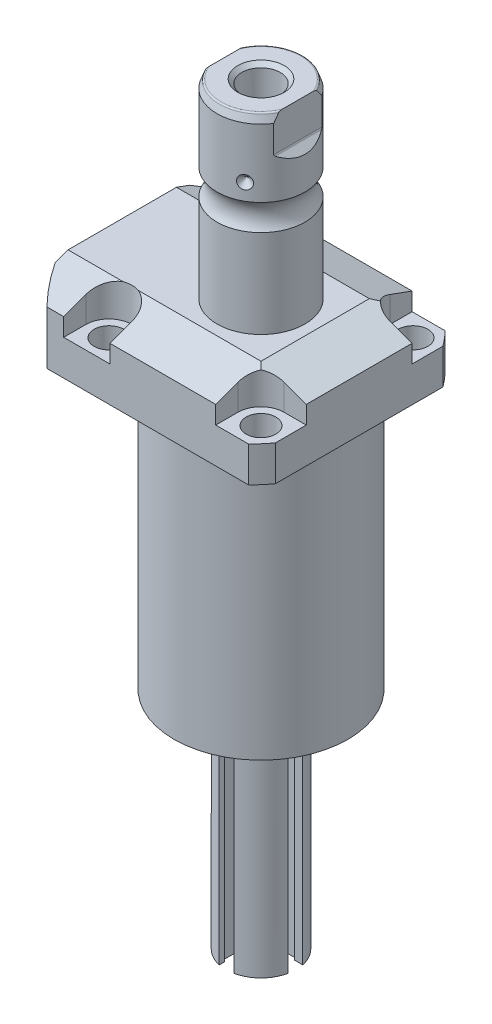
from build123d import *

# Parameters (mm, degrees)
SKETCH1_W                = 70.866
SKETCH1_H                = 85.496
EXTRUDE1_DEPTH           = 122.047
SKETCH2_OUTSIDE_W        = 120.498
SKETCH2_OUTSIDE_H        = 105.868
SKETCH2_OUTSIDE_R        = 50.8
CUT_EXTRUDE1_DEPTH       = 123.047
SKETCH3_W                = 45.1992
SKETCH3_H                = 97.028
FILLET1_R                = 0.381
CUT_EXTRUDE2_DEPTH       = 12.243
CUT_EXTRUDE9_START       = -51.063
CUT_EXTRUDE9_DEPTH       = 87.496
CUT_EXTRUDE7_DEPTH       = 36.433
CUT_EXTRUDE7_DEPTH_BACK  = 36.433
SKETCH10_R               = 1.1811
SKETCH17_W               = 5.3594
SKETCH17_H               = 12.776
HOLE1_AT_2_COUNT         = 2
HOLE1_AT_2_PITCH         = 54.864
HOLE1_AT_3_COUNT         = 2
HOLE1_AT_3_PITCH         = 77.589412886
HOLE1_AT_4_COUNT         = 2
HOLE1_AT_4_PITCH         = 54.864
CHAMFER1_SIZE            = 0.635
FILLET2_R                = 0.635
CIRPATTERN1_COUNT        = 3
CUT_EXTRUDE10_DEPTH      = 36.433
CUT_EXTRUDE10_DEPTH_BACK = 36.433
CHAMFER2_SIZE            = 1.4351
SKETCH33_R               = 2.7051
BOSS_EXTRUDE1_DEPTH      = 2.9972
CIRPATTERN2_COUNT        = 3
CUT_EXTRUDE11_DEPTH      = 70.612
CIRPATTERN3_COUNT        = 4
SKETCH35_R               = 3.4925
CUT_EXTRUDE15_DEPTH      = 7.62
CIRPATTERN4_COUNT        = 4
CUT_EXTRUDE16_DEPTH      = 1.27
CIRPATTERN5_COUNT        = 3
SKETCH39_R               = 1.7272
CUT_EXTRUDE17_DEPTH      = 2.54
CIRPATTERN6_COUNT        = 12


with BuildPart() as part:
    # Sketch1 → Extrude1 (new body)
    with BuildSketch(Plane(origin=(0, 0, 0), x_dir=(0, 0, 1), z_dir=(0, -1, 0))):
        with Locations((0, 7.315)):
            Rectangle(SKETCH1_W, SKETCH1_H)
    extrude(amount=-EXTRUDE1_DEPTH)

    # Sketch2 outside → Cut-Extrude1 (cut, through all)
    with BuildSketch(Plane.XZ):
        with Locations((-7.315, 0)):
            Rectangle(SKETCH2_OUTSIDE_W, SKETCH2_OUTSIDE_H)
        with Locations((-5.4102, 0)):
            Circle(SKETCH2_OUTSIDE_R, mode=Mode.SUBTRACT)
    extrude(amount=-CUT_EXTRUDE1_DEPTH, mode=Mode.SUBTRACT)

    # Sketch3 → Cut-Revolve1 (revolve, cut)
    with BuildSketch(Plane(origin=(0, 0, 0), x_dir=(0, 0, -1), z_dir=(1, 0, 0))):
        with Locations((53.9941, 48.514)):
            Rectangle(SKETCH3_W, SKETCH3_H)
    revolve(axis=Axis((0, -93.345, 0), (0, 1, 0)), mode=Mode.SUBTRACT)

    # Fillet1
    fillet1_edges = [part.edges().sort_by_distance(p)[0] for p in [
        (0, 97.028, 31.3945),
    ]]
    fillet(fillet1_edges, radius=FILLET1_R)

    # Sketch4 → Cut-Extrude2 (cut)
    with BuildSketch(Plane(origin=(0, 122.047, 0), x_dir=(-1, 0, 0), z_dir=(0, 1, 0))):
        with BuildLine():
            Line((-19.1008, -35.433), (-19.1008, -27.432))
            ThreePointArc((-19.1008, -27.432), (-21.540951985, -21.540951985), (-27.432, -19.1008))
            Line((-27.432, -19.1008), (-35.433, -19.1008))
            Line((-35.433, -19.1008), (-35.433, -35.433))
            Line((-35.433, -35.433), (-19.1008, -35.433))
        make_face()
        with BuildLine():
            Line((35.7632, -35.433), (19.1008, -35.433))
            Line((19.1008, -35.433), (19.1008, -27.432))
            ThreePointArc((19.1008, -27.432), (27.432, -19.1008), (35.7632, -27.432))
            Line((35.7632, -27.432), (35.7632, -35.433))
        make_face()
        with BuildLine():
            Line((19.1008, 35.433), (19.1008, 27.432))
            ThreePointArc((19.1008, 27.432), (27.432, 19.1008), (35.7632, 27.432))
            Line((35.7632, 27.432), (35.7632, 35.433))
            Line((35.7632, 35.433), (19.1008, 35.433))
        make_face()
        with BuildLine():
            Line((-27.432, 19.1008), (-35.433, 19.1008))
            Line((-35.433, 19.1008), (-35.433, 35.433))
            Line((-35.433, 35.433), (-19.1008, 35.433))
            Line((-19.1008, 35.433), (-19.1008, 27.432))
            ThreePointArc((-19.1008, 27.432), (-21.540951985, 21.540951985), (-27.432, 19.1008))
        make_face()
    extrude(amount=-CUT_EXTRUDE2_DEPTH, mode=Mode.SUBTRACT)

    # Sketch5 → Cut-Extrude9 (cut)
    with BuildSketch(Plane(origin=(0, 0, 0), x_dir=(0, 0, -1), z_dir=(1, 0, 0)).offset(CUT_EXTRUDE9_START)):
        Polygon((-19.558, 122.047), (-35.433, 116.268972531), (-35.433, 122.047), align=None)
    cut_extrude9 = extrude(amount=CUT_EXTRUDE9_DEPTH, mode=Mode.SUBTRACT)

    # Mirror1: Cut-Extrude9 across plane
    add(cut_extrude9.mirror(Plane.XY), mode=Mode.SUBTRACT)

    # Sketch9 → Cut-Extrude7 (cut, two sides)
    with BuildSketch(Plane.XY) as cut_extrude7_sk:
        Polygon((19.558, 122.047), (35.433, 116.268972531), (35.433, 122.047), align=None)
    extrude(amount=CUT_EXTRUDE7_DEPTH, mode=Mode.SUBTRACT)
    extrude(cut_extrude7_sk.sketch, amount=-CUT_EXTRUDE7_DEPTH_BACK, mode=Mode.SUBTRACT)

    # Sketch20 → Cut-Revolve4 (revolve, cut)
    with BuildSketch(Plane(origin=(-35.0774, 88.9, -18.1102), x_dir=(0, 1, 0), z_dir=(1, 0, 0)), mode=Mode.PRIVATE) as cut_revolve4_sk:
        Polygon((8.128, 38.3413), (9.5758, 38.3413), (9.5758, 35.8902), (10.5918, 35.8902), (10.5918, 33.8836), (21.5646, 33.8836), (21.5646, 32.639), (8.128, 32.639), align=None)
    cut_revolve4 = revolve(cut_revolve4_sk.sketch.rotate(Axis((-35.0774, 81.620304954, 14.5288), (0, 1, 0)), 180), axis=Axis((-35.0774, 81.620304954, 14.5288), (0, 1, 0)), mode=Mode.SUBTRACT)  # turned: the seam where the file's is

    # Mirror10: Cut-Revolve4 across plane
    add(cut_revolve4.mirror(Plane.XY), mode=Mode.SUBTRACT)

    # Sketch15 → Revolve3 (revolve)
    with BuildSketch(Plane(origin=(0, 0, 0), x_dir=(0, 0, -1), z_dir=(1, 0, 0)), mode=Mode.PRIVATE) as revolve3_sk:
        with BuildLine():
            Line((0, 122.047), (15.875, 122.047))
            Line((15.875, 122.047), (15.875, 153.89010643))
            ThreePointArc((15.875, 153.89010643), (14.3256, 158.5972), (15.875, 163.30429357))
            Line((15.875, 163.30429357), (15.875, 187.78219416))
            Line((15.875, 187.78219416), (14.81184082, 190.7032))
            Line((14.81184082, 190.7032), (0, 190.7032))
            Line((0, 190.7032), (0, 122.047))
        make_face()
    revolve(revolve3_sk.sketch.rotate(Axis((0, 250.290824608, 0), (0, -1, 0)), 180), axis=Axis((0, 250.290824608, 0), (0, -1, 0)))  # turned: the seam where the file's is

    # Sketch17 → Hole1 (revolve, cut)
    with BuildSketch(Plane(origin=(27.432, 109.804, -27.432), x_dir=(0, 0, 1), z_dir=(1, 0, 0))):
        with Locations((2.6797, 6.388)):
            Rectangle(SKETCH17_W, SKETCH17_H)
    hole1 = revolve(axis=Axis((27.432, -0.196, -27.432), (0, 1, 0)), mode=Mode.SUBTRACT)

    # Hole1 at 2: Hole1 ×2
    with Locations(*[(0, 0, i * HOLE1_AT_2_PITCH) for i in range(1, HOLE1_AT_2_COUNT)]):
        add(hole1, mode=Mode.SUBTRACT)

    # Hole1 at 3: Hole1 ×2
    with Locations(*[Vector(-0.707106781, 0, 0.707106781) * (i * HOLE1_AT_3_PITCH) for i in range(1, HOLE1_AT_3_COUNT)]):
        add(hole1, mode=Mode.SUBTRACT)

    # Hole1 at 4: Hole1 ×2
    with Locations(*[(-i * HOLE1_AT_4_PITCH, 0, 0) for i in range(1, HOLE1_AT_4_COUNT)]):
        add(hole1, mode=Mode.SUBTRACT)

    # Chamfer1
    chamfer1_edges = [part.edges().sort_by_distance(p)[0] for p in [
        (-35.0774, 99.4918, 15.7734),
        (-35.0774, 99.4918, -15.7734),
    ]]
    chamfer(chamfer1_edges, length=CHAMFER1_SIZE)

    # Sketch21 → Cut-Revolve5 (revolve, cut)
    with BuildSketch(Plane.XZ.offset(-109.5248)):
        Polygon((-50.063, -1.9304), (-49.809, -1.9304), (-49.809, -6.7564), (-47.2563, -7.440393904), (-46.695693904, -8.001), (-30.759, -8.001), (-30.759, -12.9794), (-50.063, -12.9794), align=None)
    cut_revolve5 = revolve(axis=Axis((-57.549532301, 109.5248, -12.9794), (1, 0, 0)), mode=Mode.SUBTRACT)

    # Mirror13: Cut-Revolve5 across plane
    add(cut_revolve5.mirror(Plane.XY), mode=Mode.SUBTRACT)

    # Fillet2
    fillet2_edges = [part.edges().sort_by_distance(p)[0] for p in [
        (0, 190.7032, -14.81184082),
    ]]
    fillet(fillet2_edges, radius=FILLET2_R)

    # Sketch26 → Cut-Revolve7 (revolve, cut)
    with BuildSketch(Plane.XY, mode=Mode.PRIVATE) as cut_revolve7_sk:
        Polygon((-15.875, 171.6782), (-13.462, 169.2652), (-15.875, 169.2652), align=None)
    cut_revolve7 = revolve(cut_revolve7_sk.sketch.rotate(Axis((-39.772000707, 169.2652, 0), (1, 0, 0)), 90), axis=Axis((-39.772000707, 169.2652, 0), (1, 0, 0)), mode=Mode.SUBTRACT)  # turned: the seam where the file's is

    # CirPattern1: Cut-Revolve7 ×3 about axis
    cirpattern1_axis = Axis((0, 250.290824608, 0), (0, 1, 0))
    for i in range(1, CIRPATTERN1_COUNT):
        add(cut_revolve7.rotate(cirpattern1_axis, i * 360 / CIRPATTERN1_COUNT), mode=Mode.SUBTRACT)

    # Sketch27 → Hole2 (revolve, cut)
    with BuildSketch(Plane(origin=(0, 190.7032, 0), x_dir=(0, 0, 1), z_dir=(1, 0, 0))):
        Polygon((0, 0), (0, 28.812118634), (6.9469, 24.638), (6.9469, 0), align=None)
    revolve(axis=Axis((0, 194.947399587, 0), (0, -1, 0)), mode=Mode.SUBTRACT)

    # Sketch29 → Cut-Extrude10 (cut, two sides)
    with BuildSketch(Plane.XY) as cut_extrude10_sk:
        with BuildLine():
            Line((13.284, 190.7032), (13.284, 178.0032))
            ThreePointArc((13.284, 178.0032), (13.342003912, 177.711594643), (13.507185078, 177.464383558))
            Line((13.507185078, 177.464383558), (16.332, 174.639568636))
            Line((16.332, 174.639568636), (16.332, 190.7032))
            Line((16.332, 190.7032), (13.284, 190.7032))
        make_face()
        with BuildLine():
            Line((-16.332, 190.7032), (-13.284, 190.7032))
            Line((-13.284, 190.7032), (-13.284, 178.0032))
            ThreePointArc((-13.284, 178.0032), (-13.342003912, 177.711594643), (-13.507185078, 177.464383558))
            Line((-13.507185078, 177.464383558), (-16.332, 174.639568636))
            Line((-16.332, 174.639568636), (-16.332, 190.7032))
        make_face()
    extrude(amount=CUT_EXTRUDE10_DEPTH, mode=Mode.SUBTRACT)
    extrude(cut_extrude10_sk.sketch, amount=-CUT_EXTRUDE10_DEPTH_BACK, mode=Mode.SUBTRACT)

    # Chamfer2
    chamfer2_edges = [part.edges().sort_by_distance(p)[0] for p in [
        (0, 190.7032, -6.9469),
    ]]
    chamfer(chamfer2_edges, length=CHAMFER2_SIZE)

    # Sketch30 → Revolve5 (revolve)
    with BuildSketch(Plane.XY, mode=Mode.PRIVATE) as revolve5_sk:
        Polygon((0, 0), (22.225, 0), (22.225, -2.54), (12.7, -2.54), (12.7, -81.28), (0, -81.28), align=None)
    revolve(revolve5_sk.sketch.rotate(Axis((0, 75.404549087, 0), (0, -1, 0)), 90), axis=Axis((0, 75.404549087, 0), (0, -1, 0)))  # turned: the seam where the file's is

    # Sketch33 → Boss-Extrude1 (add)
    with BuildSketch(Plane.XZ.offset(2.54)):
        with Locations(Location((19.431, 0, 0), (0, 0, 90))):  # turned: the seam where the file's is
            Circle(SKETCH33_R)
    boss_extrude1 = extrude(amount=BOSS_EXTRUDE1_DEPTH)

    # CirPattern2: Boss-Extrude1 ×3 about axis
    cirpattern2_axis = Axis((0, 0, 0), (0, 1, 0))
    for i in range(1, CIRPATTERN2_COUNT):
        add(boss_extrude1.rotate(cirpattern2_axis, i * 360 / CIRPATTERN2_COUNT))

    # Sketch34 → Cut-Extrude11 (cut)
    with BuildSketch(Plane.XZ.offset(81.28)):
        Polygon((13.335, -2.6416), (9.525, -2.6416), (9.525, -3.4925), (6.223, -3.4925), (6.223, 3.4925), (10.546286756, 3.4925), (10.546286756, 2.6416), (13.335, 2.6416), align=None)
    cut_extrude11 = extrude(amount=-CUT_EXTRUDE11_DEPTH, mode=Mode.SUBTRACT)

    # CirPattern3: Cut-Extrude11 ×4 about axis
    cirpattern3_axis = Axis((0, 0, 0), (0, 1, 0))
    for i in range(1, CIRPATTERN3_COUNT):
        add(cut_extrude11.rotate(cirpattern3_axis, i * 360 / CIRPATTERN3_COUNT), mode=Mode.SUBTRACT)

    # Sketch35 → Cut-Extrude15 (cut)
    with BuildSketch(Plane.XY.offset(6.223)):
        with Locations((0, -10.668)):
            Circle(SKETCH35_R)
    cut_extrude15 = extrude(amount=CUT_EXTRUDE15_DEPTH, mode=Mode.SUBTRACT)

    # CirPattern4: Cut-Extrude15 ×4 about axis
    cirpattern4_axis = Axis((0, 75.404549087, 0), (0, 1, 0))
    for i in range(1, CIRPATTERN4_COUNT):
        add(cut_extrude15.rotate(cirpattern4_axis, i * 360 / CIRPATTERN4_COUNT), mode=Mode.SUBTRACT)

    # Sketch37 → Cut-Extrude16 (cut)
    with BuildSketch(Plane.XZ.offset(5.5372)):
        Polygon((19.431, 1.2446), (20.14728, 1.2446), (20.865850145, 0), (20.14728, -1.2446), (18.71168029, -1.2446), (17.993110145, 0), (18.71168029, 1.2446), align=None)
    cut_extrude16 = extrude(amount=-CUT_EXTRUDE16_DEPTH, mode=Mode.SUBTRACT)

    # CirPattern5: Cut-Extrude16 ×3 about axis
    cirpattern5_axis = Axis((0, 0, 0), (0, 1, 0))
    for i in range(1, CIRPATTERN5_COUNT):
        add(cut_extrude16.rotate(cirpattern5_axis, i * 360 / CIRPATTERN5_COUNT), mode=Mode.SUBTRACT)

    # Sketch39 → Cut-Extrude17 (cut)
    with BuildSketch(Plane.XZ.offset(2.54)):
        with Locations(Location((19.431, 0, 0), (0, 0, 270))):  # turned: the seam where the file's is
            Circle(SKETCH39_R)
    cut_extrude17 = extrude(amount=-CUT_EXTRUDE17_DEPTH, mode=Mode.SUBTRACT)

    # CirPattern6: Cut-Extrude17 ×12 about axis
    cirpattern6_axis = Axis((0, 0, 0), (0, 1, 0))
    for i in range(1, CIRPATTERN6_COUNT):
        add(cut_extrude17.rotate(cirpattern6_axis, i * 360 / CIRPATTERN6_COUNT), mode=Mode.SUBTRACT)


with BuildPart() as body_2:
    # Sketch10 → Revolve4 (revolve)
    with BuildSketch(Plane(origin=(-35.0774, 88.9, -18.1102), x_dir=(0, 1, 0), z_dir=(1, 0, 0))):
        with Locations((8.3947, 8.1026)):
            Circle(SKETCH10_R)
    revolve(axis=Axis((-35.0774, 87.86749, -14.5288), (0, 1, 0)))


with BuildPart() as body_3:
    # Mirror12: mirrored copy
    add(body_2.part.mirror(Plane.XY))


solid = Compound([part.part, body_2.part, body_3.part])
